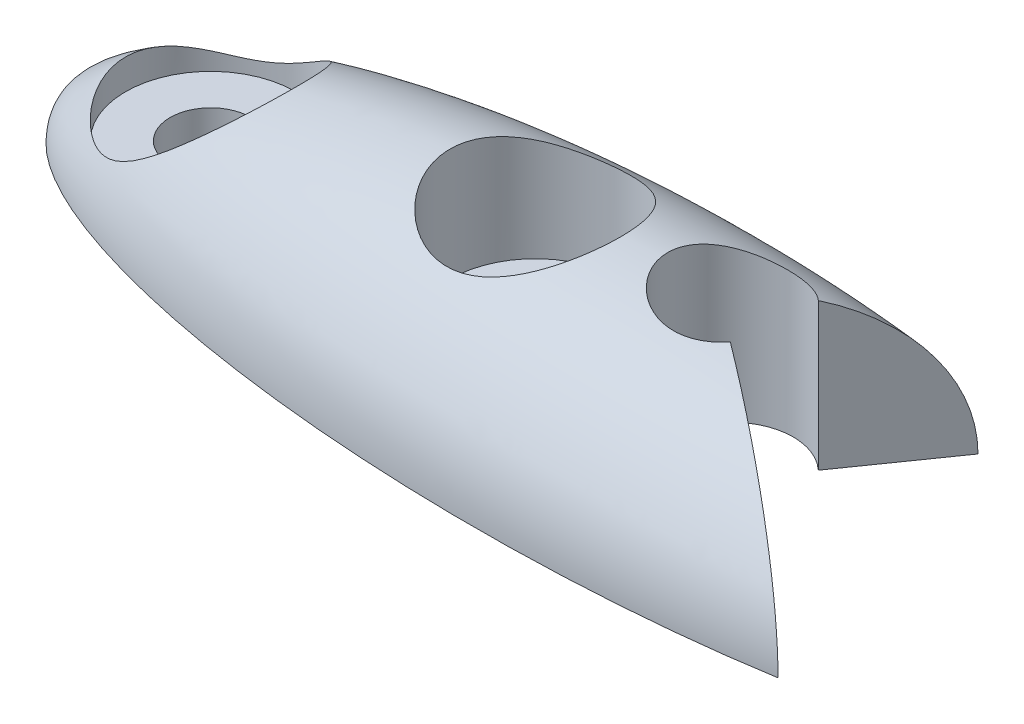
from build123d import *

# Parameters (mm, degrees)
SKETCH2_W               = 50.634745493
SKETCH2_H               = 13.07277583
CUT_EXTRUDE1_DEPTH      = 5.0000001
CUT_EXTRUDE1_DEPTH_BACK = 5.0000001
SKETCH3_R               = 1
CUT_EXTRUDE2_DEPTH      = 5.0000001
SKETCH4_R               = 2.1
CUT_EXTRUDE3_DEPTH      = 4.0000001
SKETCH5_R               = 1.5
CUT_EXTRUDE4_DEPTH      = 5.0000001
CUT_EXTRUDE5_DEPTH      = 1.0000001
CUT_EXTRUDE5_DEPTH_BACK = 5.0000001


with BuildPart() as part:
    # Sketch1 → Revolve1 (revolve)
    with BuildSketch(Plane.XY):
        with BuildLine():
            Line((-14, 0), (14, 0))
            add(Edge.make_bspline(
                [(14, 0), (14, 4), (0, 4), (-14, 4), (-14, 0)],
                knots=[0, 0, 0, 1.570796327, 1.570796327, 3.141592654, 3.141592654, 3.141592654], degree=2, weights=[1, 0.707106781, 1, 0.707106781, 1]))
        make_face()
    revolve(axis=Axis((-14, 0, 0), (1, 0, 0)))

    # Sketch2 → Cut-Extrude1 (cut, two sides)
    with BuildSketch(Plane.XY) as cut_extrude1_sk:
        with Locations((-1.598405816, -6.536387915)):
            Rectangle(SKETCH2_W, SKETCH2_H)
    extrude(amount=CUT_EXTRUDE1_DEPTH, mode=Mode.SUBTRACT)
    extrude(cut_extrude1_sk.sketch, amount=-CUT_EXTRUDE1_DEPTH_BACK, mode=Mode.SUBTRACT)

    # Sketch3 → Cut-Extrude2 (cut, through all)
    with BuildSketch(Plane.XZ):
        with Locations((-10.5, 0)):
            Circle(SKETCH3_R)
        with Locations((-2.5, 0)):
            Circle(SKETCH3_R)
    extrude(amount=-CUT_EXTRUDE2_DEPTH, mode=Mode.SUBTRACT)

    # Sketch4 → Cut-Extrude3 (cut, through all)
    with BuildSketch(Plane(origin=(0, 1, 0), x_dir=(-1, 0, 0), z_dir=(0, -1, 0))):
        with Locations((10.5, 0)):
            Circle(SKETCH4_R)
        with Locations((2.5, 0)):
            Circle(SKETCH4_R)
    extrude(amount=-CUT_EXTRUDE3_DEPTH, mode=Mode.SUBTRACT)

    # Sketch5 → Cut-Extrude4 (cut, through all)
    with BuildSketch(Plane.XZ):
        with Locations((2, -0.36)):
            Circle(SKETCH5_R)
    extrude(amount=-CUT_EXTRUDE4_DEPTH, mode=Mode.SUBTRACT)

    # Sketch6 → Cut-Extrude5 (cut, two sides)
    with BuildSketch(Plane.XZ) as cut_extrude5_sk:
        with BuildLine():
            Line((6.957274385, 3.471120893), (2, 0))
            Line((2, 0), (4.642362064, -3.773684114))
            add(Edge.make_bspline(
                [(4.642362064, -3.773684114), (14, -2.833952984), (14, 0)],
                knots=[5.050385136, 5.050385136, 5.050385136, 6.283185307, 6.283185307, 6.283185307], degree=2, weights=[1, 0.815964855, 1]))
            add(Edge.make_bspline(
                [(14, 0), (14, 2.318798314), (6.957274385, 3.471120893)],
                knots=[0, 0, 0, 1.05071793, 1.05071793, 1.05071793], degree=2, weights=[1, 0.865143968, 1]))
        make_face()
    extrude(amount=CUT_EXTRUDE5_DEPTH, mode=Mode.SUBTRACT)
    extrude(cut_extrude5_sk.sketch, amount=-CUT_EXTRUDE5_DEPTH_BACK, mode=Mode.SUBTRACT)


solid = part.part
